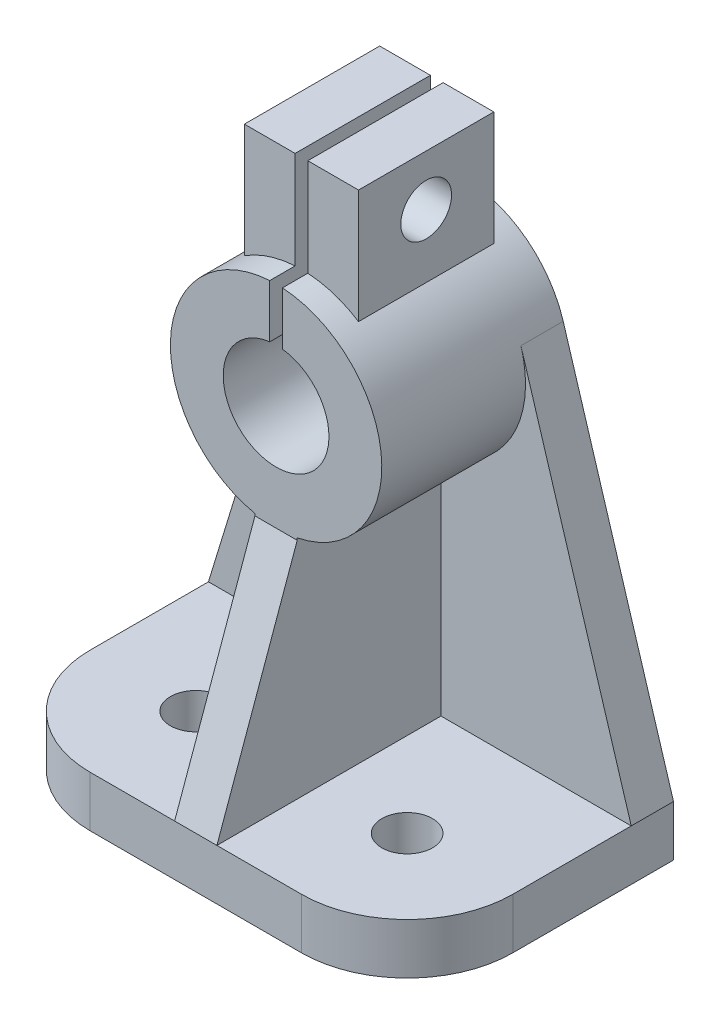
from build123d import *

# Parameters (mm, degrees)
SKETCH3_W                 = 100
SKETCH3_H                 = 63
BOSS_EXTRUDE2_DEPTH       = 12
FILLET1_R                 = 25
SKETCH4_R                 = 6
CUT_EXTRUDE1_DEPTH        = 61.301326685
BOSS_EXTRUDE3_DEPTH       = 10
BOSS_EXTRUDE4_DEPTH       = 44
SKETCH6_R                 = 12.5
CUT_EXTRUDE2_DEPTH        = 133.894695154
BOSS_EXTRUDE5_REACH       = 152.121
BOSS_EXTRUDE5_END_RADIUS  = 25
SKETCH12_W                = 27
SKETCH12_H                = 32
SKETCH13_W                = 3
SKETCH13_H                = 75
CUT_EXTRUDE3_DEPTH        = 44
SKETCH16_R                = 6
CUT_EXTRUDE4_DEPTH        = 156.140259121
BOSS_EXTRUDE14_DEPTH      = 5
BOSS_EXTRUDE15_REACH      = 95.922
BOSS_EXTRUDE15_END_RADIUS = 25
SKETCH20_W                = 10
SKETCH20_H                = 34


with BuildPart() as part:
    # Sketch3 → Boss-Extrude2 (new body)
    with BuildSketch(Plane(origin=(0, 0, 0), x_dir=(1, 0, 0), z_dir=(0, 1, 0))):
        Rectangle(SKETCH3_W, SKETCH3_H)
    extrude(amount=BOSS_EXTRUDE2_DEPTH)

    # Fillet1
    fillet1_edges = [part.edges().sort_by_distance(p)[0] for p in [
        (50, 6, 31.5),
        (-50, 6, 31.5),
    ]]
    fillet(fillet1_edges, radius=FILLET1_R)

    # Sketch4 → Cut-Extrude1 (cut, through all)
    with BuildSketch(Plane(origin=(0, 12, 0), x_dir=(1, 0, 0), z_dir=(0, 1, 0))):
        with Locations((-25, -6.5)):
            Circle(SKETCH4_R)
        with Locations((25, -6.5)):
            Circle(SKETCH4_R)
    extrude(amount=-CUT_EXTRUDE1_DEPTH, mode=Mode.SUBTRACT)

    # Sketch5 → Boss-Extrude3 (add)
    with BuildSketch(Plane(origin=(0, 0, -31.5), x_dir=(-1, 0, 0), z_dir=(0, 0, -1))):
        with BuildLine():
            Line((-50, 12), (50, 12))
            Line((50, 12), (23.906779363, 97.312038053))
            ThreePointArc((23.906779363, 97.312038053), (0, 115), (-23.906779363, 97.312038053))
            Line((-23.906779363, 97.312038053), (-50, 12))
        make_face()
    extrude(amount=-BOSS_EXTRUDE3_DEPTH)

    # Sketch5_3 → Boss-Extrude4 (add)
    with BuildSketch(Plane(origin=(0, 0, -31.5), x_dir=(-1, 0, 0), z_dir=(0, 0, -1))):
        with BuildLine():
            ThreePointArc((-23.906779363, 97.312038053), (-3.696654969, 65.274815632), (25, 90))
            ThreePointArc((25, 90), (24.725184368, 93.696654969), (23.906779363, 97.312038053))
            ThreePointArc((23.906779363, 97.312038053), (0, 115), (-23.906779363, 97.312038053))
        make_face()
    extrude(amount=-BOSS_EXTRUDE4_DEPTH)

    # Sketch6 → Cut-Extrude2 (cut, through all)
    with BuildSketch(Plane.XY.offset(12.5)):
        with Locations((0, 90)):
            Circle(SKETCH6_R)
    extrude(amount=-CUT_EXTRUDE2_DEPTH, mode=Mode.SUBTRACT)

    # Boss-Extrude5: up to this cylinder (the profile starts outside it)
    boss_extrude5_end = Plane(origin=(0, 90, -9.5), z_dir=(0, 0, -1)) * Cylinder(BOSS_EXTRUDE5_END_RADIUS, 355.242, mode=Mode.PRIVATE)
    # Sketch12 → Boss-Extrude5 (add, up to the surface)
    with BuildSketch(Plane(origin=(0, 138, 0), x_dir=(1, 0, 0), z_dir=(0, 1, 0)), mode=Mode.PRIVATE) as boss_extrude5_sk1:
        with Locations((0, 9.5)):
            Rectangle(SKETCH12_W, SKETCH12_H)
    boss_extrude5_tool1 = extrude(boss_extrude5_sk1.sketch, amount=-BOSS_EXTRUDE5_REACH, mode=Mode.PRIVATE) - boss_extrude5_end
    add(boss_extrude5_tool1.solids().sort_by_distance((0, 138, -9.5))[0])

    # Sketch13 → Cut-Extrude3 (cut)
    with BuildSketch(Plane.XY.offset(12.5)):
        with Locations((0, 119.530992001)):
            Rectangle(SKETCH13_W, SKETCH13_H)
    extrude(amount=-CUT_EXTRUDE3_DEPTH, mode=Mode.SUBTRACT)

    # Sketch16 → Cut-Extrude4 (cut, through all)
    with BuildSketch(Plane(origin=(13.5, 0, 0), x_dir=(0, 0, -1), z_dir=(1, 0, 0))):
        with Locations((9.5, 126)):
            Circle(SKETCH16_R)
    extrude(amount=-CUT_EXTRUDE4_DEPTH, mode=Mode.SUBTRACT)



with BuildPart() as body_2:
    # Sketch19 → Boss-Extrude14 (new, symmetric)
    with BuildSketch(Plane(origin=(0, 0, 0), x_dir=(0, 0, -1), z_dir=(1, 0, 0))):
        Polygon((-31.5, 12), (21.5, 12), (21.5, 65), (-12.5, 65), align=None)
    extrude(amount=BOSS_EXTRUDE14_DEPTH, both=True)


with BuildPart() as part_1:
    add(part.part)

    add(body_2.part)  # Boss-Extrude15 merges body 2
    # Boss-Extrude15: up to this cylinder (the profile starts outside it)
    boss_extrude15_end = Plane(origin=(0, 90, -4.5), z_dir=(0, 0, -1)) * Cylinder(BOSS_EXTRUDE15_END_RADIUS, 242.844, mode=Mode.PRIVATE)
    # Sketch20 → Boss-Extrude15 (add, up to the surface)
    with BuildSketch(Plane(origin=(0, 65, 0), x_dir=(1, 0, 0), z_dir=(0, 1, 0)), mode=Mode.PRIVATE) as boss_extrude15_sk1:
        with Locations((0, 4.5)):
            Rectangle(SKETCH20_W, SKETCH20_H)
    boss_extrude15_tool1 = extrude(boss_extrude15_sk1.sketch, amount=BOSS_EXTRUDE15_REACH, mode=Mode.PRIVATE) - boss_extrude15_end
    add(boss_extrude15_tool1.solids().sort_by_distance((0, 65, -4.5))[0])
    add(boss_extrude15_tool1.solids().sort_by_distance((0, 65, -4.5))[1])


solid = part_1.part
